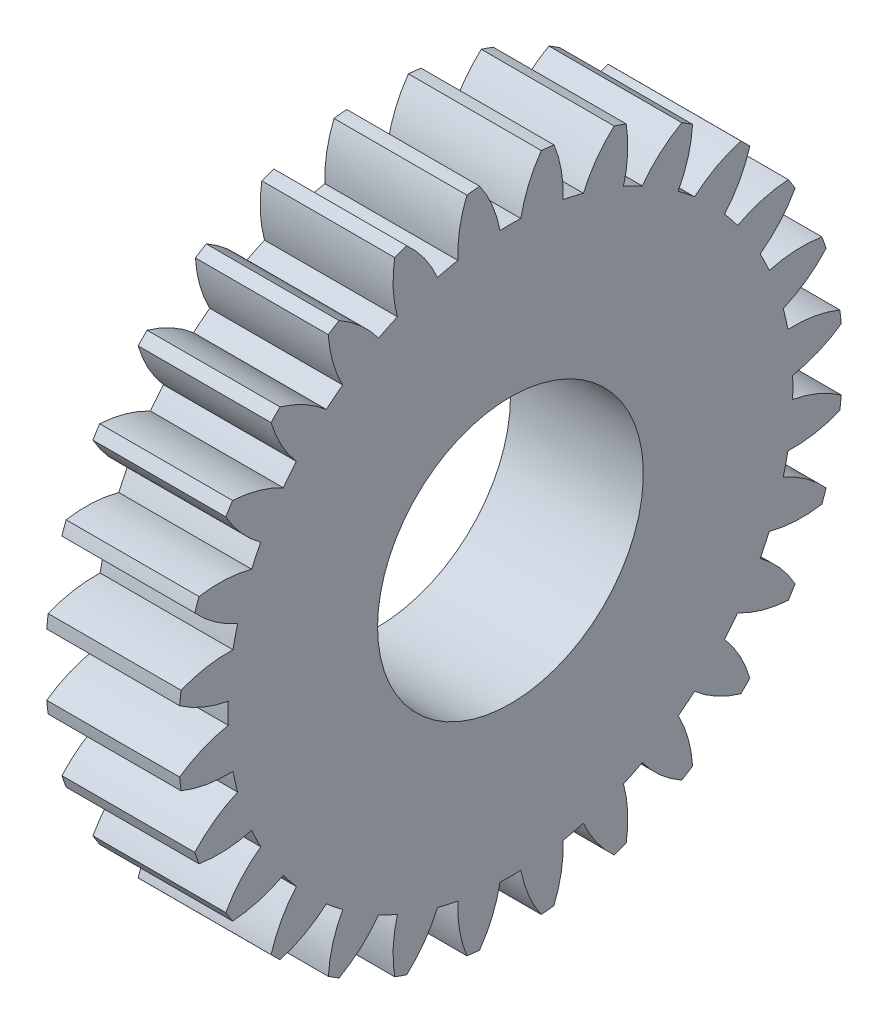
from build123d import *

# Parameters (mm, degrees)
BASPROSKE_W     = 3
BASPROSKE_H     = 7.5
TOOTHCUT_DEPTH  = 12.022703843
TEETHCUTS_COUNT = 28
TEETHCUTS_ANGLE = 347.142857143
BORSKE_R        = 3
BORE_DEPTH      = 50.0000508


with BuildPart() as part:
    # BasProSke → Base-Revolve (revolve)
    with BuildSketch(Plane(origin=(0, 0, 0), x_dir=(1, 0, 0), z_dir=(0, 1, 0)), mode=Mode.PRIVATE) as base_revolve_sk:
        with Locations((1.5, 3.75)):
            Rectangle(BASPROSKE_W, BASPROSKE_H)
    revolve(base_revolve_sk.sketch.rotate(Axis((-10, 0, 0), (1, 0, 0)), 180), axis=Axis((-10, 0, 0), (1, 0, 0)))

    # TooCutSke → ToothCut (cut, through all)
    with BuildSketch(Plane(origin=(0, 0, 0), x_dir=(0, 0, -1), z_dir=(1, 0, 0))):
        with BuildLine():
            ThreePointArc((0.235575921, 6.369645201), (0, 6.374), (-0.235575921, 6.369645201))
            ThreePointArc((-0.235575921, 6.369645201), (-0.412688204, 6.956904444), (-0.713425358, 7.491506485))
            ThreePointArc((-0.713425358, 7.491506485), (0, 7.5254), (0.713425358, 7.491506485))
            ThreePointArc((0.713425358, 7.491506485), (0.412688204, 6.956904444), (0.235575921, 6.369645201))
        make_face()
    toothcut = extrude(amount=TOOTHCUT_DEPTH, mode=Mode.SUBTRACT)

    # TeethCuts: ToothCut ×28 about axis
    teethcuts_axis = Axis((-10, 0, 0), (1, 0, 0))
    for i in range(1, TEETHCUTS_COUNT):
        add(toothcut.rotate(teethcuts_axis, i * TEETHCUTS_ANGLE / (TEETHCUTS_COUNT - 1)), mode=Mode.SUBTRACT)

    # BorSke → Bore (cut, symmetric)
    with BuildSketch(Plane(origin=(0, 0, 0), x_dir=(0, 0, -1), z_dir=(1, 0, 0))):
        with Locations(Location((0, 0, 0), (0, 0, 180))):
            Circle(BORSKE_R)
    extrude(amount=BORE_DEPTH, both=True, mode=Mode.SUBTRACT)


solid = part.part
